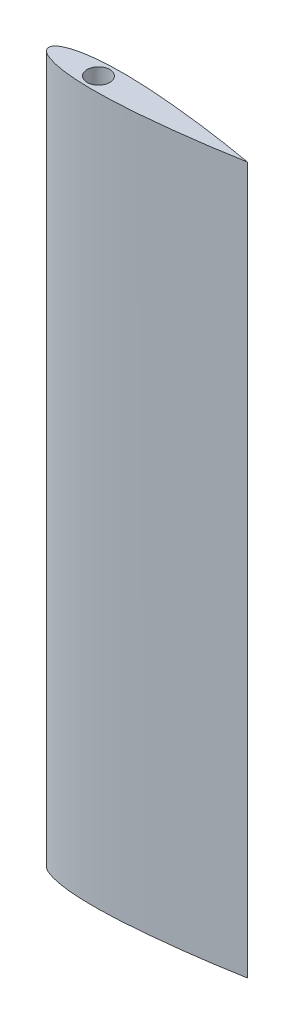
from build123d import *

# Parameters (mm, degrees)
SKETCH1_2_R        = 2.95
CUT_EXTRUDE2_DEPTH = 185.9184001


with BuildPart() as part:
    # rootSketch → Loft1 section 0
    with BuildSketch(Plane(origin=(0, 31.75, 0), x_dir=(1, 0, 0), z_dir=(0, 1, 0))):
        with BuildLine():
            add(Edge.make_bspline(
                [(0, 0), (-1.6572e-05, 0.056577364), (0.005364667, 0.148026672), (0.026073501, 0.280241396), (0.077769955, 0.452215412), (0.147060273, 0.611874915), (0.248525433, 0.785971359), (0.39236103, 0.977542518), (0.599181982, 1.195423819), (0.905829823, 1.451816919), (1.370469676, 1.757918922), (2.078266075, 2.119108524), (3.175731681, 2.542039428), (4.823252293, 2.99869744), (7.275411011, 3.452976612), (10.438659341, 3.780475746), (14.129329887, 3.929259057), (18.143568779, 3.896250983), (22.151742679, 3.722301475), (25.656241741, 3.475962342), (28.651461505, 3.213566971), (31.650711737, 2.914013348), (34.134157887, 2.639630917), (36.639458817, 2.336640809), (39.599525944, 1.953685828), (42.127939329, 1.60070159), (44.533194308, 1.24753169), (47.121130826, 0.837424538), (48.910319544, 0.545474341), (50.6553202, 0.241362714), (51.550989041, 0.081579679), (52, 0)],
                knots=[0, 0, 0, 0, 0, 0.003840944, 0.006235023, 0.009072291, 0.01219322, 0.015656839, 0.019917177, 0.025338962, 0.032592504, 0.042799388, 0.05770457, 0.079310668, 0.112503101, 0.158972616, 0.227236465, 0.295500326, 0.36376419, 0.432028053, 0.500291915, 0.534423847, 0.56855578, 0.636819643, 0.670951575, 0.705083508, 0.773347371, 0.807479302, 0.841611234, 0.875743167, 0.9098751, 0.9098751, 0.9098751, 0.9098751, 0.9098751], degree=4))
            add(Edge.make_bspline(
                [(0, 0), (-1.6572e-05, -0.056577364), (0.005364667, -0.148026672), (0.026073501, -0.280241396), (0.077769955, -0.452215412), (0.147060273, -0.611874915), (0.248525433, -0.785971359), (0.39236103, -0.977542518), (0.599181982, -1.195423819), (0.905829823, -1.451816919), (1.370469676, -1.757918922), (2.078266075, -2.119108524), (3.175731681, -2.542039428), (4.823252293, -2.99869744), (7.275411011, -3.452976612), (10.438659341, -3.780475746), (14.129329887, -3.929259057), (18.143568779, -3.896250983), (22.151742679, -3.722301475), (25.656241741, -3.475962342), (28.651461505, -3.213566971), (31.650711737, -2.914013348), (34.134157887, -2.639630917), (36.639458817, -2.336640809), (39.599525944, -1.953685828), (42.127939329, -1.60070159), (44.533194308, -1.24753169), (47.121130826, -0.837424538), (48.910319544, -0.545474341), (50.6553202, -0.241362714), (51.550989041, -0.081579679), (52, 0)],
                knots=[0, 0, 0, 0, 0, 0.003840944, 0.006235023, 0.009072291, 0.01219322, 0.015656839, 0.019917177, 0.025338962, 0.032592504, 0.042799388, 0.05770457, 0.079310668, 0.112503101, 0.158972616, 0.227236465, 0.295500326, 0.36376419, 0.432028053, 0.500291915, 0.534423847, 0.56855578, 0.636819643, 0.670951575, 0.705083508, 0.773347371, 0.807479302, 0.841611234, 0.875743167, 0.9098751, 0.9098751, 0.9098751, 0.9098751, 0.9098751], degree=4))
        make_face()
    # tipSketch → Loft1 section 1
    with BuildSketch(Plane(origin=(0, 216.6684, 0), x_dir=(1, 0, 0), z_dir=(0, 1, 0))):
        with BuildLine():
            add(Edge.make_bspline(
                [(0, 0), (-1.6572e-05, 0.056577364), (0.005364667, 0.148026672), (0.026073501, 0.280241396), (0.077769955, 0.452215412), (0.147060273, 0.611874915), (0.248525433, 0.785971359), (0.39236103, 0.977542518), (0.599181982, 1.195423819), (0.905829823, 1.451816919), (1.370469676, 1.757918922), (2.078266075, 2.119108524), (3.175731681, 2.542039428), (4.823252293, 2.99869744), (7.275411011, 3.452976612), (10.438659341, 3.780475746), (14.129329887, 3.929259057), (18.143568779, 3.896250983), (22.151742679, 3.722301475), (25.656241741, 3.475962342), (28.651461505, 3.213566971), (31.650711737, 2.914013348), (34.134157887, 2.639630917), (36.639458817, 2.336640809), (39.599525944, 1.953685828), (42.127939329, 1.60070159), (44.533194308, 1.24753169), (47.121130826, 0.837424538), (48.910319544, 0.545474341), (50.6553202, 0.241362714), (51.550989041, 0.081579679), (52, 0)],
                knots=[0, 0, 0, 0, 0, 0.003840944, 0.006235023, 0.009072291, 0.01219322, 0.015656839, 0.019917177, 0.025338962, 0.032592504, 0.042799388, 0.05770457, 0.079310668, 0.112503101, 0.158972616, 0.227236465, 0.295500326, 0.36376419, 0.432028053, 0.500291915, 0.534423847, 0.56855578, 0.636819643, 0.670951575, 0.705083508, 0.773347371, 0.807479302, 0.841611234, 0.875743167, 0.9098751, 0.9098751, 0.9098751, 0.9098751, 0.9098751], degree=4))
            add(Edge.make_bspline(
                [(0, 0), (-1.6572e-05, -0.056577364), (0.005364667, -0.148026672), (0.026073501, -0.280241396), (0.077769955, -0.452215412), (0.147060273, -0.611874915), (0.248525433, -0.785971359), (0.39236103, -0.977542518), (0.599181982, -1.195423819), (0.905829823, -1.451816919), (1.370469676, -1.757918922), (2.078266075, -2.119108524), (3.175731681, -2.542039428), (4.823252293, -2.99869744), (7.275411011, -3.452976612), (10.438659341, -3.780475746), (14.129329887, -3.929259057), (18.143568779, -3.896250983), (22.151742679, -3.722301475), (25.656241741, -3.475962342), (28.651461505, -3.213566971), (31.650711737, -2.914013348), (34.134157887, -2.639630917), (36.639458817, -2.336640809), (39.599525944, -1.953685828), (42.127939329, -1.60070159), (44.533194308, -1.24753169), (47.121130826, -0.837424538), (48.910319544, -0.545474341), (50.6553202, -0.241362714), (51.550989041, -0.081579679), (52, 0)],
                knots=[0, 0, 0, 0, 0, 0.003840944, 0.006235023, 0.009072291, 0.01219322, 0.015656839, 0.019917177, 0.025338962, 0.032592504, 0.042799388, 0.05770457, 0.079310668, 0.112503101, 0.158972616, 0.227236465, 0.295500326, 0.36376419, 0.432028053, 0.500291915, 0.534423847, 0.56855578, 0.636819643, 0.670951575, 0.705083508, 0.773347371, 0.807479302, 0.841611234, 0.875743167, 0.9098751, 0.9098751, 0.9098751, 0.9098751, 0.9098751], degree=4))
        make_face()
    loft()

    # Sketch1_2 → Cut-Extrude2 (cut, through all)
    with BuildSketch(Plane(origin=(0, 31.75, 0), x_dir=(1, 0, 0), z_dir=(0, 1, 0))):
        with Locations((12.999969404, 0)):
            Circle(SKETCH1_2_R)
    extrude(amount=CUT_EXTRUDE2_DEPTH, mode=Mode.SUBTRACT)


solid = part.part
